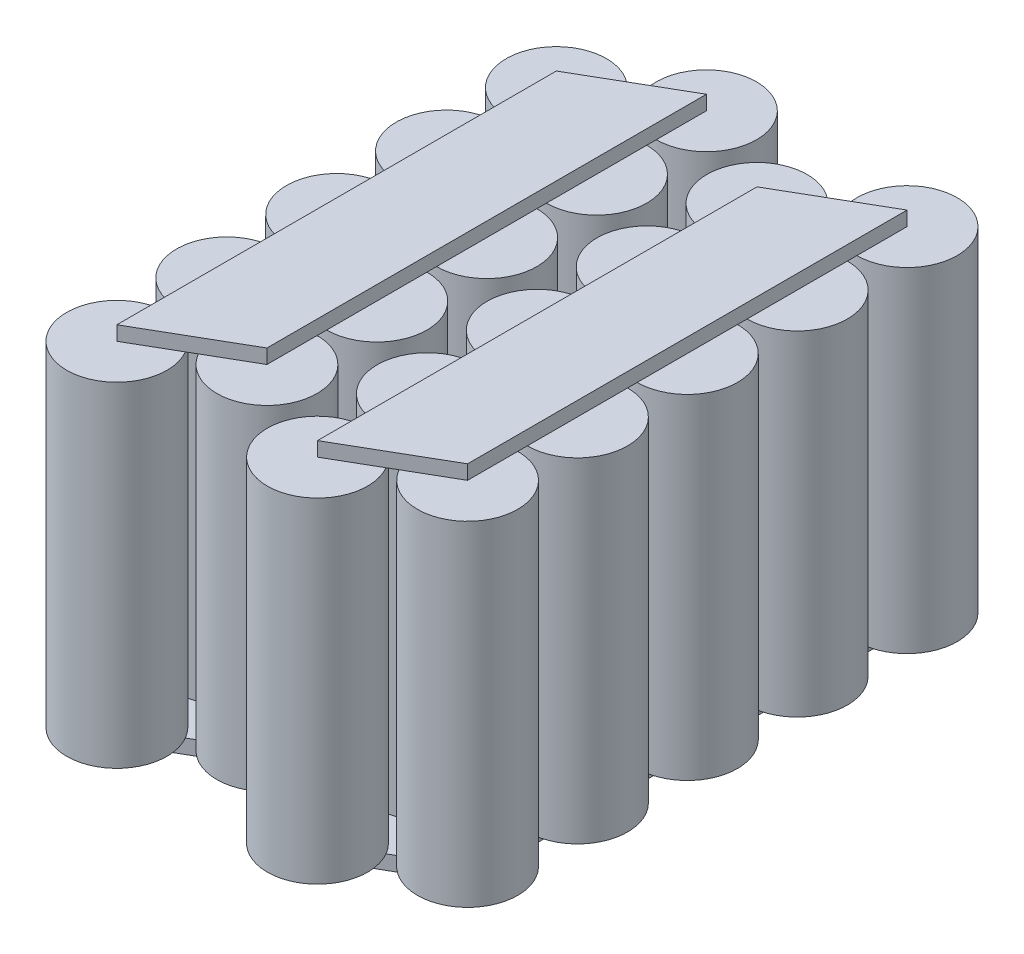
from build123d import *

# Parameters (mm, degrees)
SKETCH1_R                    = 10.5
MOLICELLL_21700_4S5P_DEPTH   = 35
MOLICELLL_21700_4S5P_2_DEPTH = 35
LPATTERN1_COUNT              = 5
LPATTERN1_PITCH              = 23
LPATTERN2_COUNT              = 2
LPATTERN2_PITCH              = 42
TOP_BUS_BAR_DEPTH            = 3
TOP_BUS_BAR_2_DEPTH          = 3
BOTTOM_BUS_BAR_DEPTH         = 3
BOTTOM_BUS_BAR_2_DEPTH       = 3


with BuildPart() as part:
    # Sketch1 → Molicelll 21700 - 4s5p (new body, symmetric)
    with BuildSketch(Plane(origin=(0, 0, 0), x_dir=(1, 0, 0), z_dir=(0, 1, 0))):
        Circle(SKETCH1_R)
    extrude(amount=MOLICELLL_21700_4S5P_DEPTH, both=True)


with BuildPart() as body_2:
    # Sketch1 → Molicelll 21700 - 4s5p 2 (new body, symmetric)
    with BuildSketch(Plane(origin=(0, 0, 0), x_dir=(1, 0, 0), z_dir=(0, 1, 0))):
        with Locations((19.918584287, 11.5)):
            Circle(SKETCH1_R)
    extrude(amount=MOLICELLL_21700_4S5P_2_DEPTH, both=True)


with BuildPart() as lpattern1_1:
    # LPattern1: pattern copy
    add(part.part.moved(Location(Vector(0, 0, 1) * (1 * LPATTERN1_PITCH))))


with BuildPart() as lpattern1_2:
    # LPattern1: pattern copy
    add(part.part.moved(Location(Vector(0, 0, 1) * (2 * LPATTERN1_PITCH))))


with BuildPart() as lpattern1_3:
    # LPattern1: pattern copy
    add(part.part.moved(Location(Vector(0, 0, 1) * (3 * LPATTERN1_PITCH))))


with BuildPart() as lpattern1_4:
    # LPattern1: pattern copy
    add(part.part.moved(Location(Vector(0, 0, 1) * (4 * LPATTERN1_PITCH))))


with BuildPart() as lpattern1_5:
    # LPattern1: pattern copy
    add(body_2.part.moved(Location(Vector(0, 0, 1) * (1 * LPATTERN1_PITCH))))


with BuildPart() as lpattern1_6:
    # LPattern1: pattern copy
    add(body_2.part.moved(Location(Vector(0, 0, 1) * (2 * LPATTERN1_PITCH))))


with BuildPart() as lpattern1_7:
    # LPattern1: pattern copy
    add(body_2.part.moved(Location(Vector(0, 0, 1) * (3 * LPATTERN1_PITCH))))


with BuildPart() as lpattern1_8:
    # LPattern1: pattern copy
    add(body_2.part.moved(Location(Vector(0, 0, 1) * (4 * LPATTERN1_PITCH))))


with BuildPart() as lpattern2_1:
    # LPattern2: pattern copy
    add(lpattern1_8.part.moved(Location(Vector(1, 0, 0) * (1 * LPATTERN2_PITCH))))


with BuildPart() as lpattern2_2:
    # LPattern2: pattern copy
    add(lpattern1_4.part.moved(Location(Vector(1, 0, 0) * (1 * LPATTERN2_PITCH))))


with BuildPart() as lpattern2_3:
    # LPattern2: pattern copy
    add(lpattern1_7.part.moved(Location(Vector(1, 0, 0) * (1 * LPATTERN2_PITCH))))


with BuildPart() as lpattern2_4:
    # LPattern2: pattern copy
    add(lpattern1_3.part.moved(Location(Vector(1, 0, 0) * (1 * LPATTERN2_PITCH))))


with BuildPart() as lpattern2_5:
    # LPattern2: pattern copy
    add(lpattern1_6.part.moved(Location(Vector(1, 0, 0) * (1 * LPATTERN2_PITCH))))


with BuildPart() as lpattern2_6:
    # LPattern2: pattern copy
    add(lpattern1_2.part.moved(Location(Vector(1, 0, 0) * (1 * LPATTERN2_PITCH))))


with BuildPart() as lpattern2_7:
    # LPattern2: pattern copy
    add(lpattern1_5.part.moved(Location(Vector(1, 0, 0) * (1 * LPATTERN2_PITCH))))


with BuildPart() as lpattern2_8:
    # LPattern2: pattern copy
    add(lpattern1_1.part.moved(Location(Vector(1, 0, 0) * (1 * LPATTERN2_PITCH))))


with BuildPart() as lpattern2_9:
    # LPattern2: pattern copy
    add(body_2.part.moved(Location(Vector(1, 0, 0) * (1 * LPATTERN2_PITCH))))


with BuildPart() as lpattern2_10:
    # LPattern2: pattern copy
    add(part.part.moved(Location(Vector(1, 0, 0) * (1 * LPATTERN2_PITCH))))


with BuildPart() as body_21:
    # Sketch2 → Top Bus Bar (new body)
    with BuildSketch(Plane(origin=(0, 35, 0), x_dir=(1, 0, 0), z_dir=(0, 1, 0))):
        Polygon((0, 0), (19.918584287, 11.5), (19.918584287, -80.5), (0, -92), align=None)
    extrude(amount=TOP_BUS_BAR_DEPTH)


with BuildPart() as body_22:
    # Sketch2 → Top Bus Bar 2 (new body)
    with BuildSketch(Plane(origin=(0, 35, 0), x_dir=(1, 0, 0), z_dir=(0, 1, 0))):
        Polygon((42, 0), (61.918584287, 11.5), (61.918584287, -80.5), (42, -92), align=None)
    extrude(amount=TOP_BUS_BAR_2_DEPTH)


with BuildPart() as body_23:
    # Sketch3 → Bottom Bus Bar (new body)
    with BuildSketch(Plane.XZ.offset(35)):
        Polygon((0, 92), (19.918584287, 80.5), (19.918584287, -11.5), (0, 0), align=None)
    extrude(amount=BOTTOM_BUS_BAR_DEPTH)


with BuildPart() as body_24:
    # Sketch3 → Bottom Bus Bar 2 (new body)
    with BuildSketch(Plane.XZ.offset(35)):
        Polygon((42, 92), (61.918584287, 80.5), (61.918584287, -11.5), (42, 0), align=None)
    extrude(amount=BOTTOM_BUS_BAR_2_DEPTH)


solid = Compound([part.part, body_2.part, lpattern1_1.part, lpattern1_2.part, lpattern1_3.part, lpattern1_4.part, lpattern1_5.part, lpattern1_6.part, lpattern1_7.part, lpattern1_8.part, lpattern2_1.part, lpattern2_2.part, lpattern2_3.part, lpattern2_4.part, lpattern2_5.part, lpattern2_6.part, lpattern2_7.part, lpattern2_8.part, lpattern2_9.part, lpattern2_10.part, body_21.part, body_22.part, body_23.part, body_24.part])
